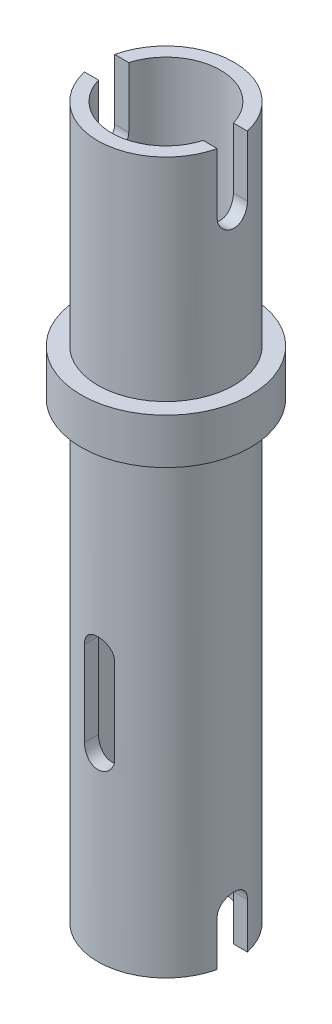
from build123d import *

# Parameters (mm, degrees)
SKETCH1_R           = 2.8
BOSS_EXTRUDE1_DEPTH = 1.5
SKETCH2_R           = 2.25
BOSS_EXTRUDE2_DEPTH = 7
SKETCH3_R           = 2.25
BOSS_EXTRUDE3_DEPTH = 15
CUT_EXTRUDE1_DEPTH  = 103.8
SKETCH5_R           = 1.8
CUT_EXTRUDE2_DEPTH  = 116.0000001
CUT_EXTRUDE3_DEPTH  = 13.8


with BuildPart() as part:
    # Sketch1 → Boss-Extrude1 (new body)
    with BuildSketch(Plane(origin=(0, 0, 0), x_dir=(1, 0, 0), z_dir=(0, 1, 0))):
        Circle(SKETCH1_R)
    extrude(amount=BOSS_EXTRUDE1_DEPTH)

    # Sketch2 → Boss-Extrude2 (add)
    with BuildSketch(Plane(origin=(0, 1.5, 0), x_dir=(1, 0, 0), z_dir=(0, 1, 0))):
        Circle(SKETCH2_R)
    extrude(amount=BOSS_EXTRUDE2_DEPTH)

    # Sketch3 → Boss-Extrude3 (add)
    with BuildSketch(Plane.XZ):
        Circle(SKETCH3_R)
    extrude(amount=BOSS_EXTRUDE3_DEPTH)

    # Sketch4 → Cut-Extrude1 (cut, through all)
    with BuildSketch(Plane(origin=(100, 0, 0), x_dir=(0, 0, -1), z_dir=(1, 0, 0))):
        with BuildLine():
            Line((0.5, -13.5), (0.5, -15))
            ThreePointArc((0.5, -15), (0, -15.5), (-0.5, -15))
            Line((-0.5, -15), (-0.5, -13.5))
            ThreePointArc((-0.5, -13.5), (0, -13), (0.5, -13.5))
        make_face()
        with BuildLine():
            Line((-0.5, 6.5), (-0.5, 8.5))
            ThreePointArc((-0.5, 8.5), (0, 9), (0.5, 8.5))
            Line((0.5, 8.5), (0.5, 6.5))
            ThreePointArc((0.5, 6.5), (0, 6), (-0.5, 6.5))
        make_face()
    extrude(amount=-CUT_EXTRUDE1_DEPTH, mode=Mode.SUBTRACT)

    # Sketch5 → Cut-Extrude2 (cut, through all)
    with BuildSketch(Plane(origin=(0, 100, 0), x_dir=(1, 0, 0), z_dir=(0, 1, 0))):
        Circle(SKETCH5_R)
    extrude(amount=-CUT_EXTRUDE2_DEPTH, mode=Mode.SUBTRACT)

    # Sketch6 → Cut-Extrude3 (cut, through all)
    with BuildSketch(Plane.XY.offset(10)):
        with BuildLine():
            Line((-0.5, -9), (-0.5, -6.191505656))
            ThreePointArc((-0.5, -6.191505656), (0, -5.691505656), (0.5, -6.191505656))
            Line((0.5, -6.191505656), (0.5, -9))
            ThreePointArc((0.5, -9), (0, -9.5), (-0.5, -9))
        make_face()
    extrude(amount=-CUT_EXTRUDE3_DEPTH, mode=Mode.SUBTRACT)


solid = part.part
